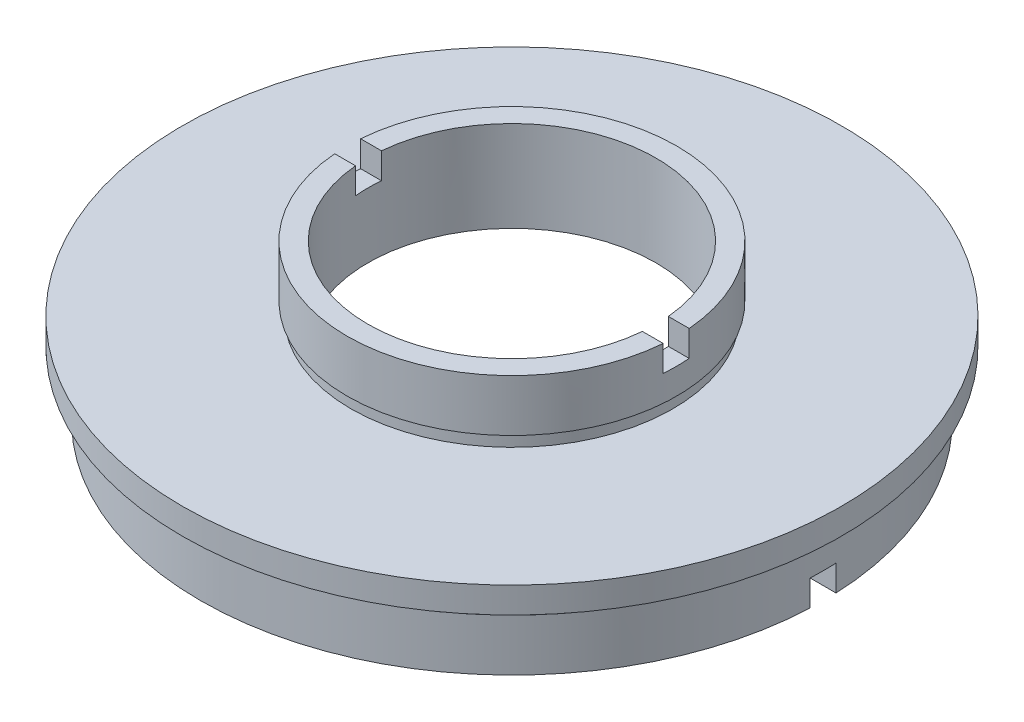
from build123d import *

# Parameters (mm, degrees)
SKETCH_2_W          = 2
SKETCH_2_H          = 3.593987872
SKETCH_2_H_2        = 6.667892238
CUT_EXTRUDE_1_DEPTH = 39.5


with BuildPart() as part:
    # 草图1 → 旋转1 (revolve)
    with BuildSketch(Plane.XY, mode=Mode.PRIVATE) as revolve_1_sk:
        Polygon((-11.1, 12), (-12.7, 12), (-12.7, 8), (-12.4, 8), (-12.4, 7), (-25.4, 7), (-25.4, 5), (-23.5, 5), (-23.5, 4), (-24, 4), (-24, 0), (-20.5, 0), (-20.5, 4), (-21.1, 4), (-21.1, 5), (-11.1, 5), align=None)
    revolve(revolve_1_sk.sketch.rotate(Axis((0, 22.677499451, 0), (0, -1, 0)), 270), axis=Axis((0, 22.677499451, 0), (0, -1, 0)))  # turned: the seam where the file's is

    # 草图2 → 切除-拉伸1 (cut, symmetric)
    with BuildSketch(Plane(origin=(0, 0, 0), x_dir=(0, 0, -1), z_dir=(1, 0, 0))):
        with Locations((0, 11.796993936)):
            Rectangle(SKETCH_2_W, SKETCH_2_H)
        with Locations((0, -1.333946119)):
            Rectangle(SKETCH_2_W, SKETCH_2_H_2)
    extrude(amount=CUT_EXTRUDE_1_DEPTH, both=True, mode=Mode.SUBTRACT)


solid = part.part
